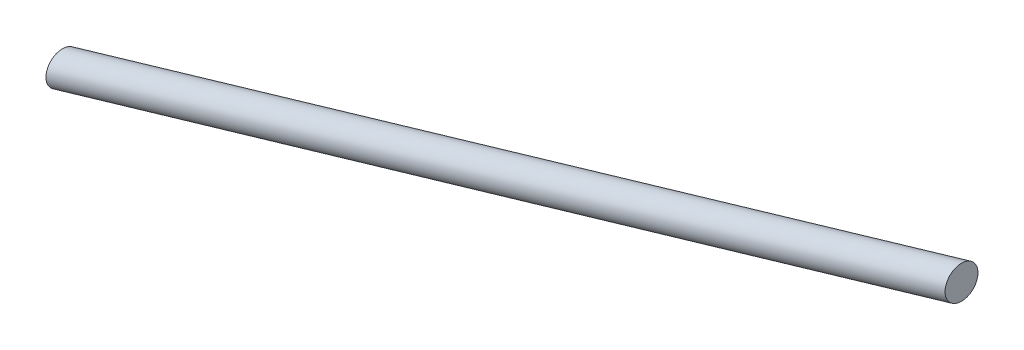
from build123d import *

# Parameters (mm, degrees)
SKETCH1_R           = 19.05
BOSS_EXTRUDE1_DEPTH = 1082.548


with BuildPart() as part:
    # Sketch1 → Boss-Extrude1 (new body, along a direction that is not the sketch's normal)
    with BuildSketch(Plane(origin=(0, 0, 0), x_dir=(0, 0, -1), z_dir=(1, 0, 0))):
        Circle(SKETCH1_R)
    extrude(amount=BOSS_EXTRUDE1_DEPTH, dir=(0.959552082, 0.281531173, 0))


solid = part.part
